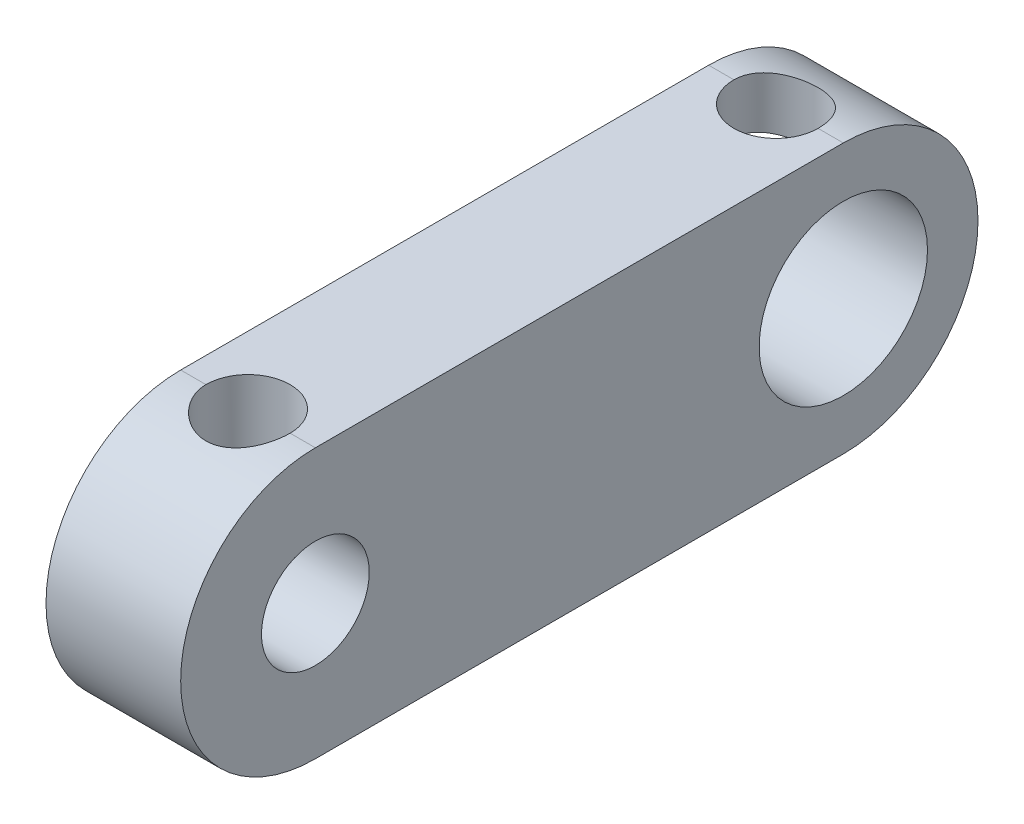
from build123d import *

# Parameters (mm, degrees)
SKETCH1_R                 = 1.6
SKETCH1_R_2               = 2.5
BOSS_EXTRUDE1_DEPTH       = 2
M3X0_5_TAPPED_HOLE1_D     = 2.5
M3X0_5_TAPPED_HOLE1_DEPTH = 5
M3X0_5_TAPPED_HOLE1_TIP   = 0.751075774


with BuildPart() as part:
    # Sketch1 → Boss-Extrude1 (new body, symmetric)
    with BuildSketch(Plane(origin=(0, 0, 0), x_dir=(0, 0, -1), z_dir=(1, 0, 0))):
        with BuildLine():
            Line((0, 4), (15.68, 4))
            ThreePointArc((15.68, 4), (19.68, 0), (15.68, -4))
            Line((15.68, -4), (0, -4))
            ThreePointArc((0, -4), (-4, 0), (0, 4))
        make_face()
        Circle(SKETCH1_R, mode=Mode.SUBTRACT)
        with Locations((15.68, 0)):
            Circle(SKETCH1_R_2, mode=Mode.SUBTRACT)
    extrude(amount=BOSS_EXTRUDE1_DEPTH, both=True)

    # M3x0.5 Tapped Hole1
    with Locations(Plane(origin=(0, 4, 0), x_dir=(1, 0, 0), z_dir=(0, 1, 0))):
        with Locations((0, 15.68), (0, 0)):
            Hole(M3X0_5_TAPPED_HOLE1_D / 2, depth=M3X0_5_TAPPED_HOLE1_DEPTH)
            with Locations((0, 0, -(M3X0_5_TAPPED_HOLE1_DEPTH + M3X0_5_TAPPED_HOLE1_TIP / 2))):  # 118° drill point
                Cone(0, M3X0_5_TAPPED_HOLE1_D / 2, M3X0_5_TAPPED_HOLE1_TIP, mode=Mode.SUBTRACT)


solid = part.part
